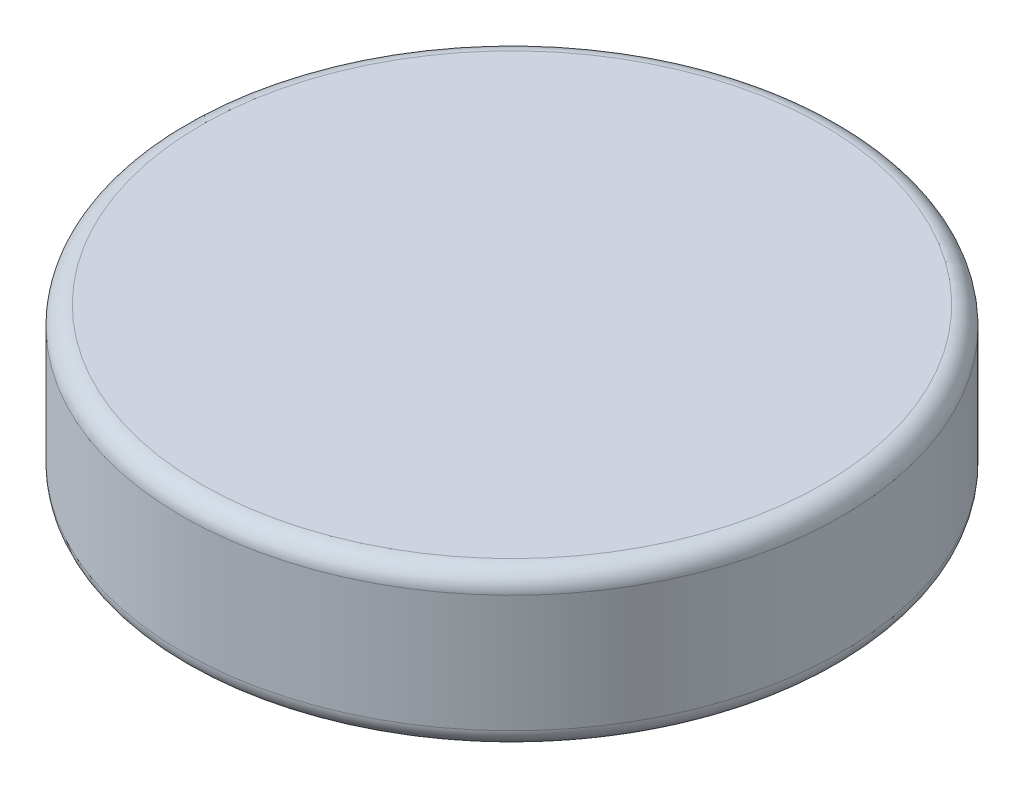
from build123d import *

# Parameters (mm, degrees)
SKETCH1_R           = 177
BOSS_EXTRUDE1_DEPTH = 83
FILLET1_R           = 10
SKETCH2_R           = 143.260231918
BOSS_EXTRUDE2_DEPTH = 15


with BuildPart() as part:
    # Sketch1 → Boss-Extrude1 (new body)
    with BuildSketch(Plane(origin=(0, 0, 0), x_dir=(1, 0, 0), z_dir=(0, 1, 0))):
        Circle(SKETCH1_R)
    extrude(amount=BOSS_EXTRUDE1_DEPTH)

    # Fillet1
    fillet1_edges = [part.edges().sort_by_distance(p)[0] for p in [
        (-177, 0, 0),
        (-177, 83, 0),
    ]]
    fillet(fillet1_edges, radius=FILLET1_R)

    # Sketch2 → Boss-Extrude2 (add)
    with BuildSketch(Plane.XZ):
        Circle(SKETCH2_R)
    extrude(amount=BOSS_EXTRUDE2_DEPTH)


solid = part.part
